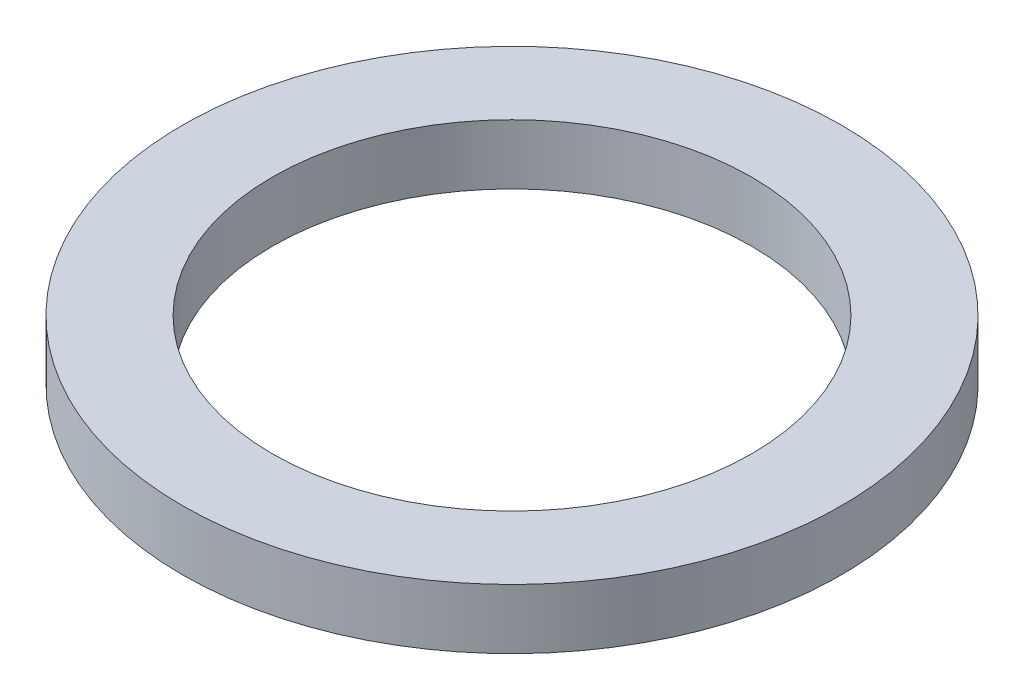
from build123d import *

# Parameters (mm, degrees)
SKETCH1_R           = 5.5
SKETCH1_R_2         = 4
BOSS_EXTRUDE1_DEPTH = 0.5


with BuildPart() as part:
    # Sketch1 → Boss-Extrude1 (new body, symmetric)
    with BuildSketch(Plane(origin=(0, 0, 0), x_dir=(1, 0, 0), z_dir=(0, 1, 0))):
        Circle(SKETCH1_R)
        Circle(SKETCH1_R_2, mode=Mode.SUBTRACT)
    extrude(amount=BOSS_EXTRUDE1_DEPTH, both=True)


solid = part.part
